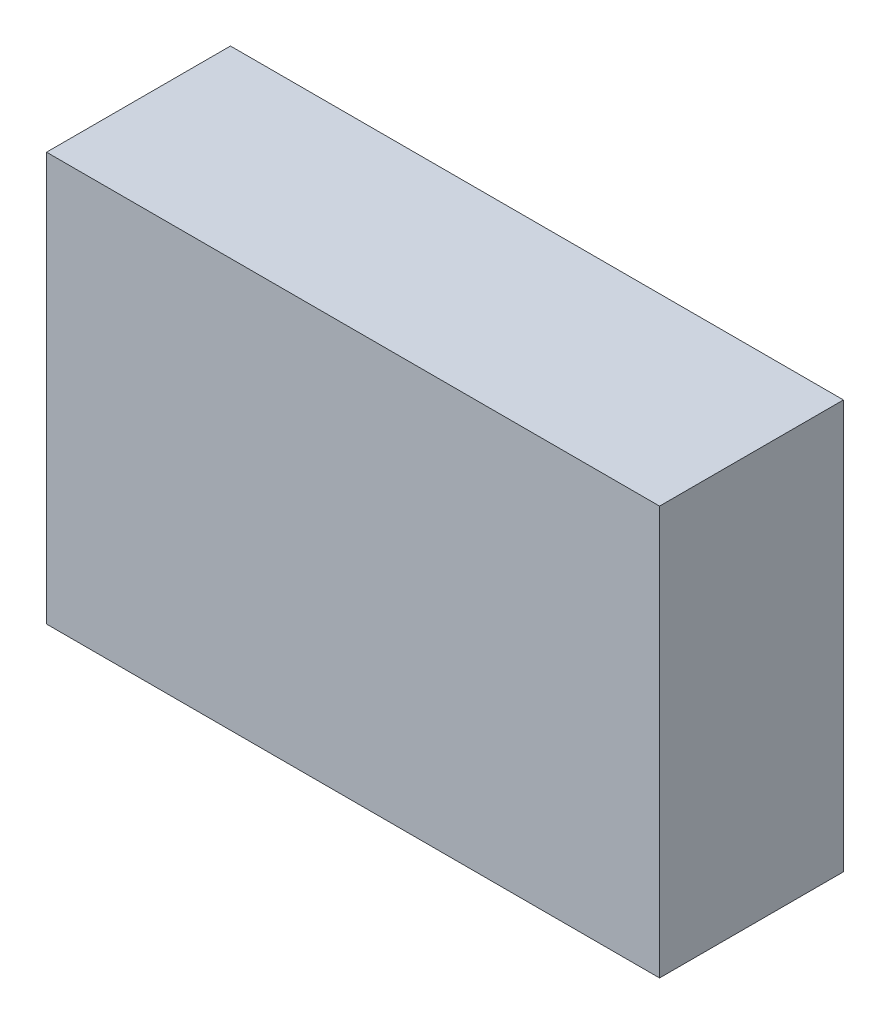
from build123d import *

# Parameters (mm, degrees)
SKETCH1_W           = 150
SKETCH1_H           = 45
BOSS_EXTRUDE1_DEPTH = 100


with BuildPart() as part:
    # Sketch1 → Boss-Extrude1 (new body)
    with BuildSketch(Plane(origin=(0, 0, 0), x_dir=(1, 0, 0), z_dir=(0, 1, 0))):
        with Locations((75, 22.5)):
            Rectangle(SKETCH1_W, SKETCH1_H)
    extrude(amount=BOSS_EXTRUDE1_DEPTH)


solid = part.part
